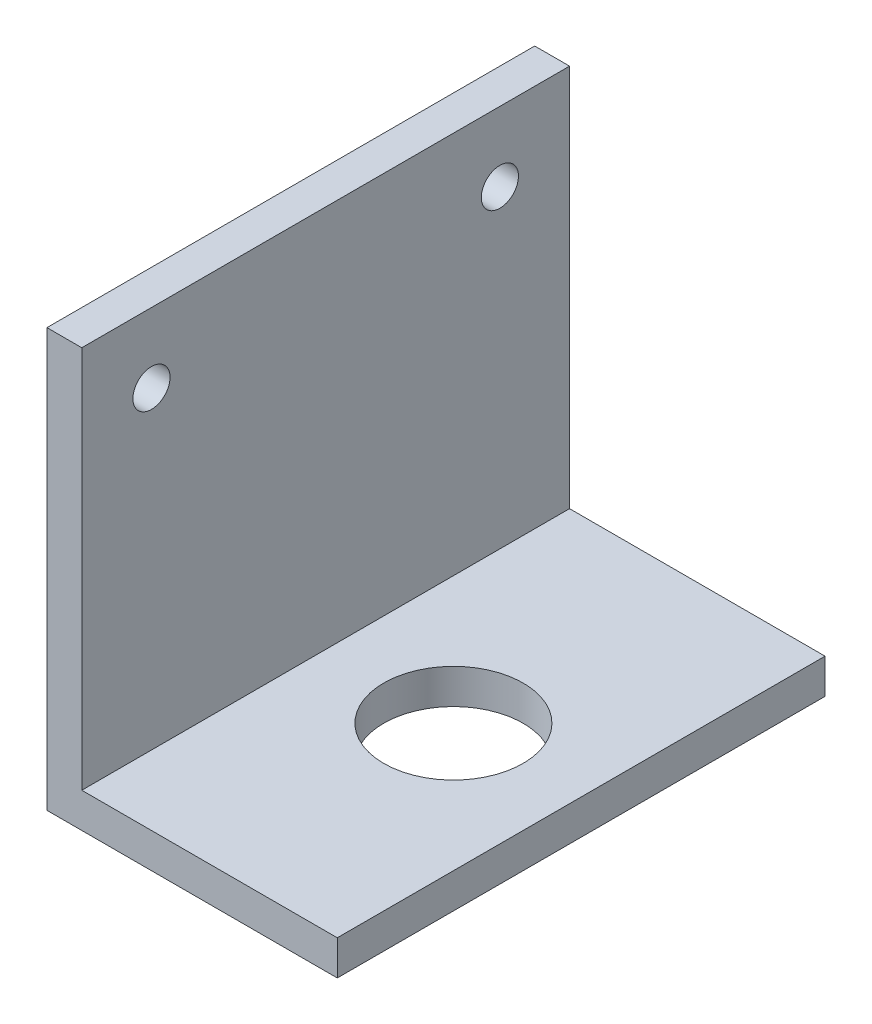
from build123d import *

# Parameters (mm, degrees)
EXTRUDE_1_DEPTH     = 42
SKETCH_2_R          = 1.6
CUT_EXTRUDE_1_DEPTH = 26
SKETCH_3_R          = 6
CUT_EXTRUDE_2_DEPTH = 4


with BuildPart() as part:
    # ｽｹｯﾁ1 → ﾎﾞｽ - 押し出し1 (new body)
    with BuildSketch(Plane.XY):
        Polygon((0, 0), (0, 36), (3, 36), (3, 3), (25, 3), (25, 0), align=None)
    extrude(amount=EXTRUDE_1_DEPTH)

    # ｽｹｯﾁ2 → ｶｯﾄ - 押し出し1 (cut, through all)
    with BuildSketch(Plane.ZY):
        with Locations((36, 30)):
            Circle(SKETCH_2_R)
        with Locations((6, 30)):
            Circle(SKETCH_2_R)
    extrude(amount=-CUT_EXTRUDE_1_DEPTH, mode=Mode.SUBTRACT)

    # ｽｹｯﾁ3 → ｶｯﾄ - 押し出し2 (cut, through all)
    with BuildSketch(Plane(origin=(0, 3, 0), x_dir=(1, 0, 0), z_dir=(0, 1, 0))):
        with Locations((14, -21)):
            Circle(SKETCH_3_R)
    extrude(amount=-CUT_EXTRUDE_2_DEPTH, mode=Mode.SUBTRACT)


solid = part.part
